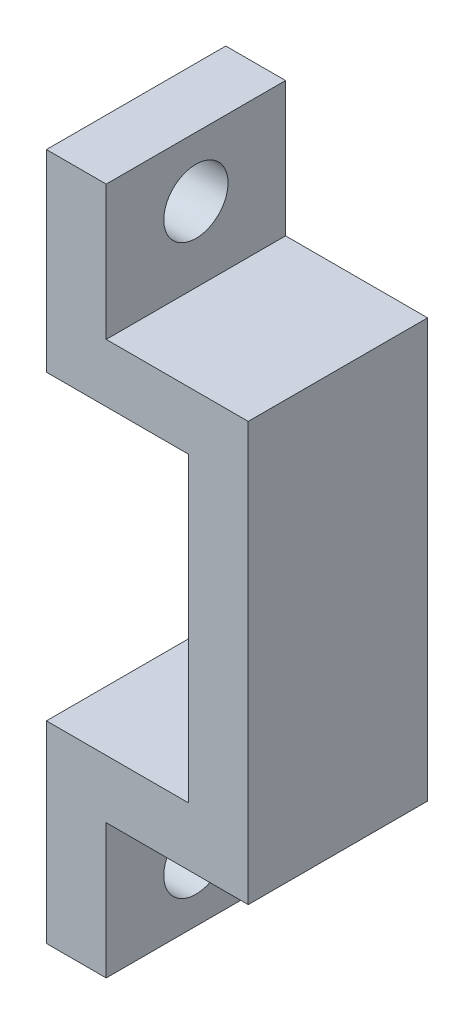
from build123d import *

# Parameters (mm, degrees)
BOSS_EXTRUDE1_DEPTH = 12
SKETCH2_R           = 2.15
CUT_EXTRUDE1_DEPTH  = 39


with BuildPart() as part:
    # Sketch1 → Boss-Extrude1 (new body)
    with BuildSketch(Plane.XY):
        Polygon((82.5, 84.667703031), (82.5, 71.767703031), (92, 71.767703031), (92, 51.567703031), (82.5, 51.567703031), (82.5, 38.667703031), (86.5, 38.667703031), (86.5, 47.667703031), (96, 47.667703031), (96, 75.667703031), (86.5, 75.667703031), (86.5, 84.667703031), align=None)
    extrude(amount=-BOSS_EXTRUDE1_DEPTH)

    # Sketch2 → Cut-Extrude1 (cut)
    with BuildSketch(Plane(origin=(86.5, 0, 0), x_dir=(0, 0, -1), z_dir=(1, 0, 0))):
        with Locations((6, 42.667703031)):
            Circle(SKETCH2_R)
        with Locations((6, 80.667703031)):
            Circle(SKETCH2_R)
    extrude(amount=-CUT_EXTRUDE1_DEPTH, mode=Mode.SUBTRACT)


solid = part.part
